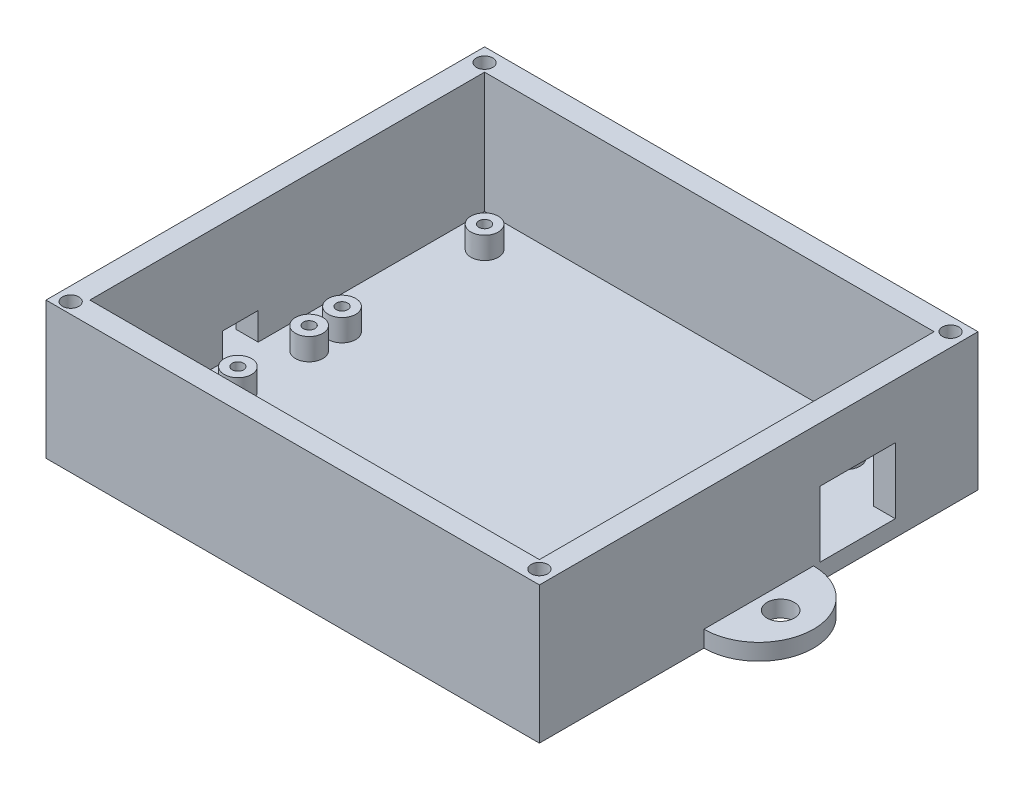
from build123d import *

# Parameters (mm, degrees)
SKETCH1_R           = 2.495486553
BOSS_EXTRUDE1_DEPTH = 3
SKETCH2_R           = 2.5
BOSS_EXTRUDE2_DEPTH = 4
SKETCH3_R           = 1.5
CUT_EXTRUDE1_DEPTH  = 3
SKETCH4_R           = 1.05
CUT_EXTRUDE2_DEPTH  = 4.5
SKETCH6_W           = 90
SKETCH6_H           = 80
SKETCH6_W_2         = 82
SKETCH6_H_2         = 72
BOSS_EXTRUDE3_DEPTH = 22
SKETCH7_W           = 13.75
SKETCH7_H           = 12
CUT_EXTRUDE3_DEPTH  = 20
SKETCH8_R           = 1.5
CUT_EXTRUDE4_DEPTH  = 10
SKETCH10_W          = 6.5
SKETCH10_H          = 5.005531991
CUT_EXTRUDE5_DEPTH  = 10


with BuildPart() as part:
    # Sketch1 → Boss-Extrude1 (new body)
    with BuildSketch(Plane(origin=(0, 0, 0), x_dir=(1, 0, 0), z_dir=(0, 1, 0))):
        with BuildLine():
            Line((-45, 40), (-10, 40))
            Line((-10, 40), (10, 40))
            Line((10, 40), (45, 40))
            Line((45, 40), (45, 10))
            ThreePointArc((45, 10), (55, 0), (45, -10))
            Line((45, -10), (45, -40))
            Line((45, -40), (10, -40))
            Line((10, -40), (-10, -40))
            Line((-10, -40), (-45, -40))
            Line((-45, -40), (-45, -10))
            ThreePointArc((-45, -10), (-55, 0), (-45, 10))
            Line((-45, 10), (-45, 40))
        make_face()
        with Locations((-49, 0)):
            Circle(SKETCH1_R, mode=Mode.SUBTRACT)
        with Locations((49, 0)):
            Circle(SKETCH1_R, mode=Mode.SUBTRACT)
    extrude(amount=BOSS_EXTRUDE1_DEPTH)

    # Sketch2 → Boss-Extrude2 (add)
    with BuildSketch(Plane(origin=(0, 3, 0), x_dir=(1, 0, 0), z_dir=(0, 1, 0))):
        with Locations((-35, 30)):
            Circle(SKETCH2_R)
        with Locations((31, 30)):
            Circle(SKETCH2_R)
        with Locations((31, 4)):
            Circle(SKETCH2_R)
        with Locations((-35, 4)):
            Circle(SKETCH2_R)
        with Locations((-35, -2)):
            Circle(SKETCH2_R)
        with Locations((31, -2)):
            Circle(SKETCH2_R)
        with Locations((-35, -15)):
            Circle(SKETCH2_R)
        with Locations((31, -15)):
            Circle(SKETCH2_R)
    extrude(amount=BOSS_EXTRUDE2_DEPTH)

    # Sketch3 → Cut-Extrude1 (cut)
    with BuildSketch(Plane(origin=(0, 3, 0), x_dir=(1, 0, 0), z_dir=(0, 1, 0))):
        with Locations((-22.5, -25.674226477)):
            Circle(SKETCH3_R)
        with Locations((22.5, -25.674226477)):
            Circle(SKETCH3_R)
    extrude(amount=-CUT_EXTRUDE1_DEPTH, mode=Mode.SUBTRACT)

    # Sketch4 → Cut-Extrude2 (cut)
    with BuildSketch(Plane(origin=(0, 7, 0), x_dir=(1, 0, 0), z_dir=(0, 1, 0))):
        with Locations((-35, 30)):
            Circle(SKETCH4_R)
        with Locations((31, 30)):
            Circle(SKETCH4_R)
        with Locations((31, 4)):
            Circle(SKETCH4_R)
        with Locations((31, -2)):
            Circle(SKETCH4_R)
        with Locations((-35, 4)):
            Circle(SKETCH4_R)
        with Locations((-35, -2)):
            Circle(SKETCH4_R)
        with Locations((-35, -15)):
            Circle(SKETCH4_R)
        with Locations((31, -15)):
            Circle(SKETCH4_R)
    extrude(amount=-CUT_EXTRUDE2_DEPTH, mode=Mode.SUBTRACT)

    # Sketch6 → Boss-Extrude3 (add)
    with BuildSketch(Plane(origin=(0, 3, 0), x_dir=(1, 0, 0), z_dir=(0, 1, 0))):
        Rectangle(SKETCH6_W, SKETCH6_H)
        Rectangle(SKETCH6_W_2, SKETCH6_H_2, mode=Mode.SUBTRACT)
    extrude(amount=BOSS_EXTRUDE3_DEPTH)

    # Sketch7 → Cut-Extrude3 (cut)
    with BuildSketch(Plane.ZY.offset(-41)):
        with Locations((-18.038625802, 9)):
            Rectangle(SKETCH7_W, SKETCH7_H)
    extrude(amount=-CUT_EXTRUDE3_DEPTH, mode=Mode.SUBTRACT)

    # Sketch8 → Cut-Extrude4 (cut)
    with BuildSketch(Plane(origin=(0, 25, 0), x_dir=(1, 0, 0), z_dir=(0, 1, 0))):
        with Locations((-42.5, 37.5)):
            Circle(SKETCH8_R)
        with Locations((42.5, 37.5)):
            Circle(SKETCH8_R)
        with Locations((-42.5, -38)):
            Circle(SKETCH8_R)
        with Locations((42.5, -37.5)):
            Circle(SKETCH8_R)
    extrude(amount=-CUT_EXTRUDE4_DEPTH, mode=Mode.SUBTRACT)

    # Sketch10 → Cut-Extrude5 (cut)
    with BuildSketch(Plane(origin=(-41, 0, 0), x_dir=(0, 0, -1), z_dir=(1, 0, 0))):
        with Locations((-8.55, 5.502765995)):
            Rectangle(SKETCH10_W, SKETCH10_H)
    extrude(amount=-CUT_EXTRUDE5_DEPTH, mode=Mode.SUBTRACT)


solid = part.part
